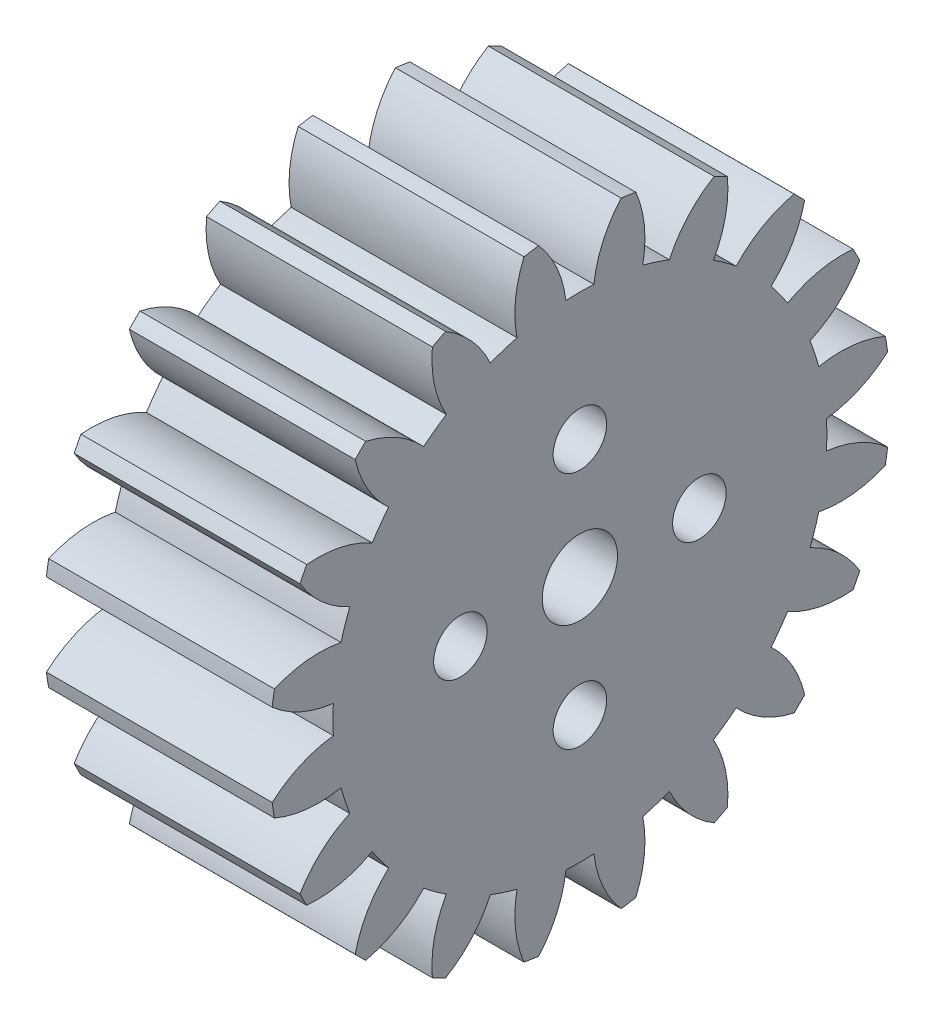
from build123d import *

# Parameters (mm, degrees)
BASPROSKE_W        = 12
BASPROSKE_H        = 16.5
TOOTHCUT_DEPTH     = 27.239283527
TEETHCUTS_COUNT    = 20
TEETHCUTS_ANGLE    = 342
BORSKE_R           = 2
BORE_DEPTH         = 50.0000508
SKETCH1_R          = 1.4224
CUT_EXTRUDE1_DEPTH = 27.055895681


with BuildPart() as part:
    # BasProSke → Base-Revolve (revolve)
    with BuildSketch(Plane(origin=(0, 0, 0), x_dir=(1, 0, 0), z_dir=(0, 1, 0)), mode=Mode.PRIVATE) as base_revolve_sk:
        with Locations((6, 8.25)):
            Rectangle(BASPROSKE_W, BASPROSKE_H)
    revolve(base_revolve_sk.sketch.rotate(Axis((-10, 0, 0), (1, 0, 0)), 180), axis=Axis((-10, 0, 0), (1, 0, 0)))

    # TooCutSke → ToothCut (cut, through all)
    with BuildSketch(Plane(origin=(0, 0, 0), x_dir=(0, 0, -1), z_dir=(1, 0, 0))):
        with BuildLine():
            ThreePointArc((0.74381438, 13.102904875), (0, 13.124), (-0.74381438, 13.102904875))
            ThreePointArc((-0.74381438, 13.102904875), (-1.226473103, 14.852072512), (-2.209965745, 16.376962373))
            ThreePointArc((-2.209965745, 16.376962373), (0, 16.5254), (2.209965745, 16.376962373))
            ThreePointArc((2.209965745, 16.376962373), (1.226473103, 14.852072512), (0.74381438, 13.102904875))
        make_face()
    toothcut = extrude(amount=TOOTHCUT_DEPTH, mode=Mode.SUBTRACT)

    # TeethCuts: ToothCut ×20 about axis
    teethcuts_axis = Axis((-10, 0, 0), (1, 0, 0))
    for i in range(1, TEETHCUTS_COUNT):
        add(toothcut.rotate(teethcuts_axis, i * TEETHCUTS_ANGLE / (TEETHCUTS_COUNT - 1)), mode=Mode.SUBTRACT)

    # BorSke → Bore (cut, symmetric)
    with BuildSketch(Plane(origin=(0, 0, 0), x_dir=(0, 0, -1), z_dir=(1, 0, 0))):
        with Locations(Location((0, 0, 0), (0, 0, 180))):
            Circle(BORSKE_R)
    extrude(amount=BORE_DEPTH, both=True, mode=Mode.SUBTRACT)

    # Sketch1 → Cut-Extrude1 (cut, through all)
    with BuildSketch(Plane(origin=(0, 0, 0), x_dir=(0, 0, -1), z_dir=(1, 0, 0))):
        with Locations((0, 6.35)):
            Circle(SKETCH1_R)
        with Locations((6.35, 0)):
            Circle(SKETCH1_R)
        with Locations((0, -6.35)):
            Circle(SKETCH1_R)
        with Locations((-6.35, 0)):
            Circle(SKETCH1_R)
    extrude(amount=CUT_EXTRUDE1_DEPTH, mode=Mode.SUBTRACT)


solid = part.part
